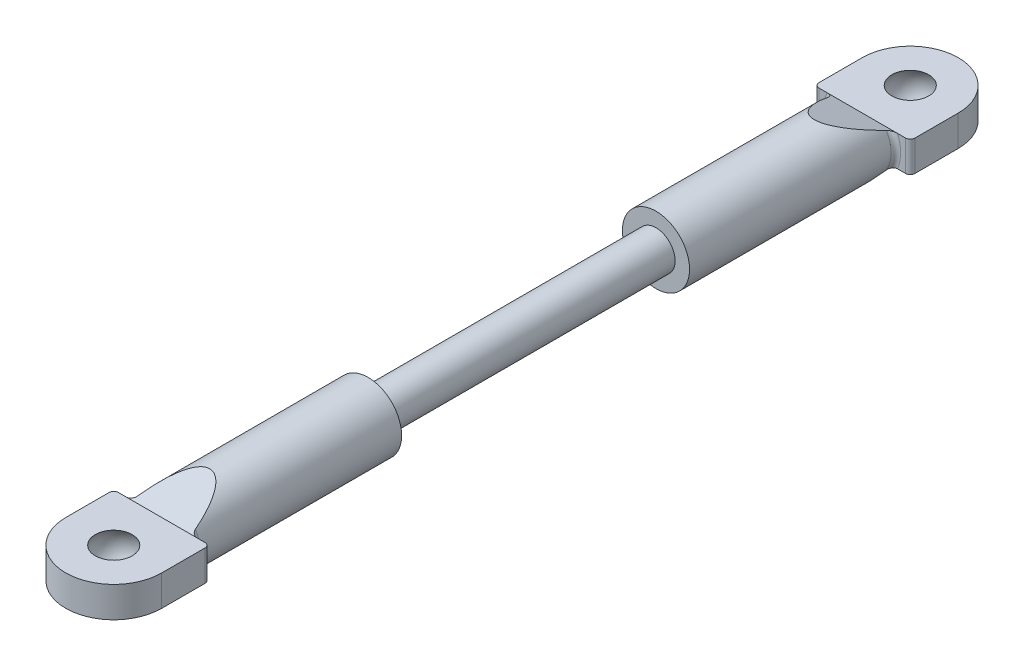
from build123d import *

# Parameters (mm, degrees)
SKETCH1_R                  = 2
SCREW_SECTION_DEPTH        = 15
SKETCH2_R                  = 3.5
BAR_SECTION_DEPTH          = 21.5
MOUNT_SECTION_DEPTH        = 1.6
BAR_TAPER_DEPTH            = 6
MOUNT_FILLET_R             = 0.5
MOUNT_FILLET_OF_MIRROR_2_R = 0.5


with BuildPart() as part:
    # Sketch1 → Screw Section (new body)
    with BuildSketch(Plane.XY):
        Circle(SKETCH1_R)
    screw_section = extrude(amount=SCREW_SECTION_DEPTH)

    # Sketch2 → Bar Section (add)
    with BuildSketch(Plane.XY.offset(15)):
        Circle(SKETCH2_R)
    bar_section = extrude(amount=BAR_SECTION_DEPTH)

    # Sketch3 → Mount Section (add, symmetric)
    with BuildSketch(Plane(origin=(0, 0, 0), x_dir=(1, 0, 0), z_dir=(0, 1, 0))):
        with BuildLine():
            Line((5, -36.5), (-5, -36.5))
            Line((-5, -36.5), (-5, -41.5))
            ThreePointArc((-5, -41.5), (0, -46.5), (5, -41.5))
            Line((5, -41.5), (5, -36.5))
        make_face()
    mount_section = extrude(amount=MOUNT_SECTION_DEPTH, both=True)

    # Sketch4 → Bar Taper (cut, symmetric)
    with BuildSketch(Plane(origin=(0, 0, 0), x_dir=(0, 0, -1), z_dir=(1, 0, 0))):
        Polygon((-31.5, -3.5), (-36.5, -1.6), (-36.5, -3.5), align=None)
        Polygon((-31.5, 3.5), (-36.5, 1.6), (-36.5, 3.5), align=None)
    bar_taper = extrude(amount=BAR_TAPER_DEPTH, both=True, mode=Mode.SUBTRACT)

    # Mount Fillet
    mount_fillet_edges = [part.edges().sort_by_distance(p)[0] for p in [
        (-5, 0, 36.5),
        (3.401842713, -0.823083322, 36.5),
        (-3.5, 0, 36.5),
        (5, 0, 36.5),
    ]]
    fillet(mount_fillet_edges, radius=MOUNT_FILLET_R)

    # Sketch6 → Ball Hole (revolve, cut)
    with BuildSketch(Plane(origin=(0, 0, 0), x_dir=(0, 0, -1), z_dir=(1, 0, 0))):
        with BuildLine():
            Line((-43.420937271, -1.6), (-41.5, -1.6))
            Line((-41.5, -1.6), (-41.5, 1.6))
            Line((-41.5, 1.6), (-43.420937271, 1.6))
            ThreePointArc((-43.420937271, 1.6), (-44, 0), (-43.420937271, -1.6))
        make_face()
    ball_hole = revolve(axis=Axis((0, -1.6, 41.5), (0, 1, 0)), mode=Mode.SUBTRACT)

    # Mirror 2: Screw Section, Bar Section, Mount Section, Bar Taper, Ball Hole across Front Plane
    add(screw_section.mirror(Plane.XY))
    add(bar_section.mirror(Plane.XY))
    add(mount_section.mirror(Plane.XY))
    add(bar_taper.mirror(Plane.XY), mode=Mode.SUBTRACT)
    add(ball_hole.mirror(Plane.XY), mode=Mode.SUBTRACT)

    # Mount Fillet of Mirror 2
    mount_fillet_of_mirror_2_edges = [part.edges().sort_by_distance(p)[0] for p in [
        (-5, 0, -36.5),
        (3.401842713, -0.823083322, -36.5),
        (-3.5, 0, -36.5),
        (5, 0, -36.5),
    ]]
    fillet(mount_fillet_of_mirror_2_edges, radius=MOUNT_FILLET_OF_MIRROR_2_R)


solid = part.part
